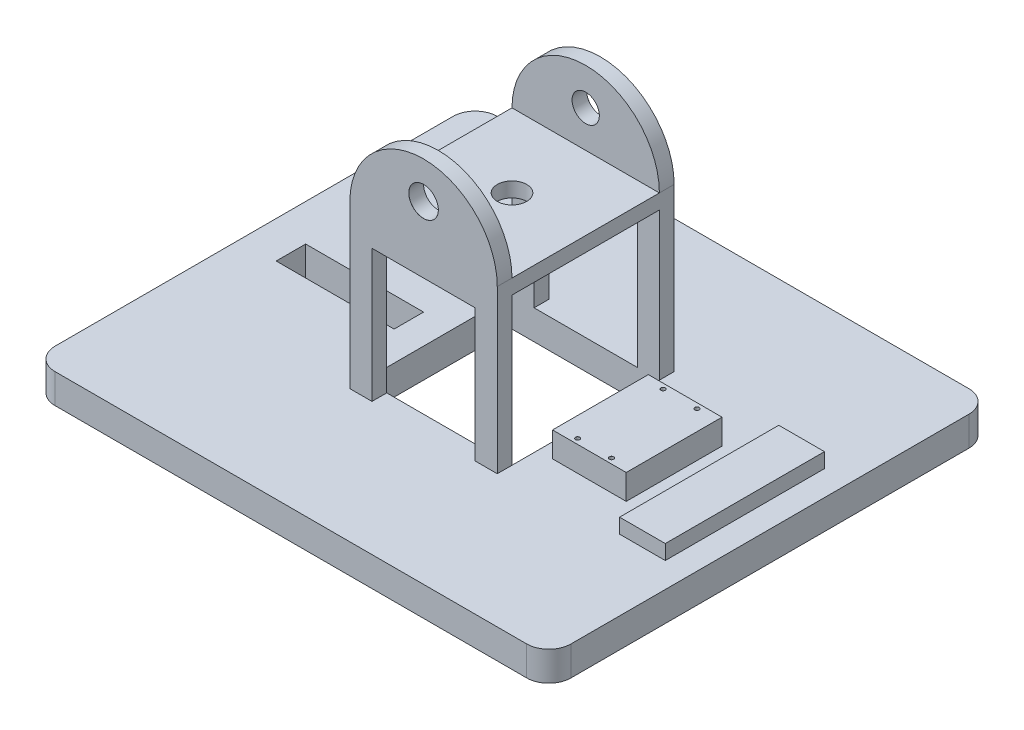
from build123d import *

# Parameters (mm, degrees)
SKETCH1_W                              = 350
SKETCH1_H                              = 300
BOSS_EXTRUDE1_DEPTH                    = 20
FILLET1_R                              = 15
SKETCH2_W                              = 100
SKETCH2_H                              = 100
CUT_EXTRUDE1_DEPTH                     = 20
BOSS_EXTRUDE2_DEPTH                    = 10
LPATTERN1_COUNT                        = 2
LPATTERN1_PITCH                        = 110
F_20_0_20_DIAMETER_HOLE2_D             = 20
F_20_0_20_DIAMETER_HOLE2_DEPTH         = 10
F_20_0_20_DIAMETER_HOLE2_CSINK_D       = 20.05
F_20_0_20_DIAMETER_HOLE2_CSINK_ANGLE   = 90
F_20_0_20_DIAMETER_HOLE2_TIP           = 6.00860619
F_18_5_18_5_DIAMETER_HOLE1_D           = 18.5
F_18_5_18_5_DIAMETER_HOLE1_DEPTH       = 10
F_18_5_18_5_DIAMETER_HOLE1_CSINK_D     = 18.55
F_18_5_18_5_DIAMETER_HOLE1_CSINK_ANGLE = 90
F_18_5_18_5_DIAMETER_HOLE1_TIP         = 5.557960726
SKETCH32_W                             = 100
SKETCH32_H                             = 10
BOSS_EXTRUDE3_DEPTH                    = 120
SKETCH37_R                             = 10
CUT_EXTRUDE2_DEPTH                     = 36.07831716
SKETCH45_W                             = 30
SKETCH45_H                             = 65
BOSS_EXTRUDE4_DEPTH                    = 17
M2_5_CLEARANCE_HOLE1_D                 = 2.9
M2_5_CLEARANCE_HOLE1_DEPTH             = 12.4
M2_5_CLEARANCE_HOLE1_CSINK_D           = 2.95
M2_5_CLEARANCE_HOLE1_CSINK_ANGLE       = 90
M2_5_CLEARANCE_HOLE1_TIP               = 0.871247898
SKETCH54_W                             = 10
SKETCH54_H                             = 65
BOSS_EXTRUDE5_DEPTH                    = 17
SKETCH55_W                             = 31
SKETCH55_H                             = 108
BOSS_EXTRUDE6_DEPTH                    = 10
SKETCH59_W                             = 80
SKETCH59_H                             = 20
CUT_EXTRUDE3_DEPTH                     = 21
SKETCH60_W                             = 70
SKETCH60_H                             = 90
CUT_EXTRUDE4_DEPTH                     = 180
SKETCH64_R                             = 3.65
BOSS_EXTRUDE7_DEPTH                    = 10
SKETCH70_R                             = 11
CUT_EXTRUDE5_DEPTH                     = 7
SKETCH75_R                             = 13
SKETCH75_R_2                           = 11
SKETCH75_R_3                           = 3.65
BOSS_EXTRUDE8_DEPTH                    = 8
SKETCH77_R                             = 11
CUT_EXTRUDE6_DEPTH                     = 7


with BuildPart() as part:
    # Sketch1 → Boss-Extrude1 (new body)
    with BuildSketch(Plane(origin=(0, 0, 0), x_dir=(1, 0, 0), z_dir=(0, 1, 0))):
        with Locations((175, -150)):
            Rectangle(SKETCH1_W, SKETCH1_H)
    extrude(amount=BOSS_EXTRUDE1_DEPTH)

    # Fillet1
    fillet1_edges = [part.edges().sort_by_distance(p)[0] for p in [
        (0, 10, 0),
        (350, 10, 0),
        (350, 10, 300),
        (0, 10, 300),
    ]]
    fillet(fillet1_edges, radius=FILLET1_R)

    # Sketch2 → Cut-Extrude1 (cut)
    with BuildSketch(Plane(origin=(0, 20, 0), x_dir=(1, 0, 0), z_dir=(0, 1, 0))):
        with Locations((175, -150)):
            Rectangle(SKETCH2_W, SKETCH2_H)
    extrude(amount=-CUT_EXTRUDE1_DEPTH, mode=Mode.SUBTRACT)

    # Sketch6 → Boss-Extrude2 (add)
    with BuildSketch(Plane.XY.offset(100)):
        with BuildLine():
            Line((125, 0), (125, 130))
            ThreePointArc((125, 130), (175, 180), (225, 130))
            Line((225, 130), (225, 0))
            Line((225, 0), (125, 0))
        make_face()
    boss_extrude2 = extrude(amount=-BOSS_EXTRUDE2_DEPTH)

    # LPattern1: Boss-Extrude2 ×2
    with Locations(*[(0, 0, i * LPATTERN1_PITCH) for i in range(1, LPATTERN1_COUNT)]):
        add(boss_extrude2)

    # Ø20.0 (20) Diameter Hole2
    with Locations(Plane.XY.offset(210)):
        with Locations((175, 155)):
            CounterSinkHole(F_20_0_20_DIAMETER_HOLE2_D / 2, F_20_0_20_DIAMETER_HOLE2_CSINK_D / 2, depth=F_20_0_20_DIAMETER_HOLE2_DEPTH, counter_sink_angle=F_20_0_20_DIAMETER_HOLE2_CSINK_ANGLE)
            with Locations((0, 0, -(F_20_0_20_DIAMETER_HOLE2_DEPTH + F_20_0_20_DIAMETER_HOLE2_TIP / 2))):  # 118° drill point
                Cone(0, F_20_0_20_DIAMETER_HOLE2_D / 2, F_20_0_20_DIAMETER_HOLE2_TIP, mode=Mode.SUBTRACT)

    # Ø18.5 (18.5) Diameter Hole1
    with Locations(Plane(origin=(0, 0, 90), x_dir=(-1, 0, 0), z_dir=(0, 0, -1))):
        with Locations((-175, 155)):
            CounterSinkHole(F_18_5_18_5_DIAMETER_HOLE1_D / 2, F_18_5_18_5_DIAMETER_HOLE1_CSINK_D / 2, depth=F_18_5_18_5_DIAMETER_HOLE1_DEPTH, counter_sink_angle=F_18_5_18_5_DIAMETER_HOLE1_CSINK_ANGLE)
            with Locations((0, 0, -(F_18_5_18_5_DIAMETER_HOLE1_DEPTH + F_18_5_18_5_DIAMETER_HOLE1_TIP / 2))):  # 118° drill point
                Cone(0, F_18_5_18_5_DIAMETER_HOLE1_D / 2, F_18_5_18_5_DIAMETER_HOLE1_TIP, mode=Mode.SUBTRACT)

    # Sketch32 → Boss-Extrude3 (add)
    with BuildSketch(Plane.XY.offset(210)):
        with Locations((175, 125)):
            Rectangle(SKETCH32_W, SKETCH32_H)
    extrude(amount=-BOSS_EXTRUDE3_DEPTH)

    # Sketch37 → Cut-Extrude2 (cut)
    with BuildSketch(Plane(origin=(0, 130, 0), x_dir=(1, 0, 0), z_dir=(0, 1, 0))):
        with Locations((175, -150)):
            Circle(SKETCH37_R)
    extrude(amount=-CUT_EXTRUDE2_DEPTH, mode=Mode.SUBTRACT)

    # Sketch45 → Boss-Extrude4 (add)
    with BuildSketch(Plane(origin=(0, 20, 0), x_dir=(1, 0, 0), z_dir=(0, 1, 0))):
        with Locations((260, -150)):
            Rectangle(SKETCH45_W, SKETCH45_H)
    extrude(amount=BOSS_EXTRUDE4_DEPTH)

    # M2.5 Clearance Hole1
    with Locations(Plane(origin=(0, 37, 0), x_dir=(1, 0, 0), z_dir=(0, 1, 0))):
        with Locations((248.5, -121), (271.5, -121), (271.5, -179), (248.5, -179)):
            CounterSinkHole(M2_5_CLEARANCE_HOLE1_D / 2, M2_5_CLEARANCE_HOLE1_CSINK_D / 2, depth=M2_5_CLEARANCE_HOLE1_DEPTH, counter_sink_angle=M2_5_CLEARANCE_HOLE1_CSINK_ANGLE)
            with Locations((0, 0, -(M2_5_CLEARANCE_HOLE1_DEPTH + M2_5_CLEARANCE_HOLE1_TIP / 2))):  # 118° drill point
                Cone(0, M2_5_CLEARANCE_HOLE1_D / 2, M2_5_CLEARANCE_HOLE1_TIP, mode=Mode.SUBTRACT)

    # Sketch54 → Boss-Extrude5 (add)
    with BuildSketch(Plane(origin=(0, 20, 0), x_dir=(1, 0, 0), z_dir=(0, 1, 0))):
        with Locations((280, -150)):
            Rectangle(SKETCH54_W, SKETCH54_H)
        with Locations((240, -150)):
            Rectangle(SKETCH54_W, SKETCH54_H)
    extrude(amount=BOSS_EXTRUDE5_DEPTH)

    # Sketch55 → Boss-Extrude6 (add)
    with BuildSketch(Plane(origin=(0, 20, 0), x_dir=(1, 0, 0), z_dir=(0, 1, 0))):
        with Locations((317.5, -150)):
            Rectangle(SKETCH55_W, SKETCH55_H)
    extrude(amount=BOSS_EXTRUDE6_DEPTH)

    # Sketch59 → Cut-Extrude3 (cut, through all)
    with BuildSketch(Plane(origin=(0, 20, 0), x_dir=(1, 0, 0), z_dir=(0, 1, 0))):
        with Locations((65, -150)):
            Rectangle(SKETCH59_W, SKETCH59_H)
    extrude(amount=-CUT_EXTRUDE3_DEPTH, mode=Mode.SUBTRACT)

    # Sketch60 → Cut-Extrude4 (cut)
    with BuildSketch(Plane.XY.offset(210)):
        with Locations((175, 65)):
            Rectangle(SKETCH60_W, SKETCH60_H)
    extrude(amount=-CUT_EXTRUDE4_DEPTH, mode=Mode.SUBTRACT)

    # Sketch64 → Boss-Extrude7 (add)
    with BuildSketch(Plane(origin=(0, 0, 0), x_dir=(-1, 0, 0), z_dir=(0, 0, -1))):
        with BuildLine():
            Line((-305, 0), (-305, -15))
            ThreePointArc((-305, -15), (-292, -28), (-279, -15))
            Line((-279, -15), (-279, 0))
            Line((-279, 0), (-305, 0))
        make_face()
        with Locations((-292, -15)):
            Circle(SKETCH64_R, mode=Mode.SUBTRACT)
    extrude(amount=-BOSS_EXTRUDE7_DEPTH)

    # Sketch70 → Cut-Extrude5 (cut)
    with BuildSketch(Plane(origin=(0, 0, 0), x_dir=(-1, 0, 0), z_dir=(0, 0, -1))):
        with Locations((-292, -15)):
            Circle(SKETCH70_R)
    extrude(amount=-CUT_EXTRUDE5_DEPTH, mode=Mode.SUBTRACT)

    # Sketch75 → Boss-Extrude8 (add)
    with BuildSketch(Plane(origin=(0, 0, 0), x_dir=(-1, 0, 0), z_dir=(0, 0, -1))):
        with Locations((-58, -15)):
            Circle(SKETCH75_R)
        with Locations((-58, -15)):
            Circle(SKETCH75_R_2, mode=Mode.SUBTRACT)
        with Locations((-58, -15)):
            Circle(SKETCH75_R_2)
        with Locations((-58, -15)):
            Circle(SKETCH75_R_3, mode=Mode.SUBTRACT)
        with BuildLine():
            Line((-71, 0), (-71, -15))
            ThreePointArc((-71, -15), (-58, -2), (-45, -15))
            Line((-45, -15), (-45, 0))
            Line((-45, 0), (-71, 0))
        make_face()
    extrude(amount=-BOSS_EXTRUDE8_DEPTH)

    # Sketch77 → Cut-Extrude6 (cut)
    with BuildSketch(Plane(origin=(0, 0, 0), x_dir=(-1, 0, 0), z_dir=(0, 0, -1))):
        with Locations((-58, -15)):
            Circle(SKETCH77_R)
    extrude(amount=-CUT_EXTRUDE6_DEPTH, mode=Mode.SUBTRACT)


solid = part.part
